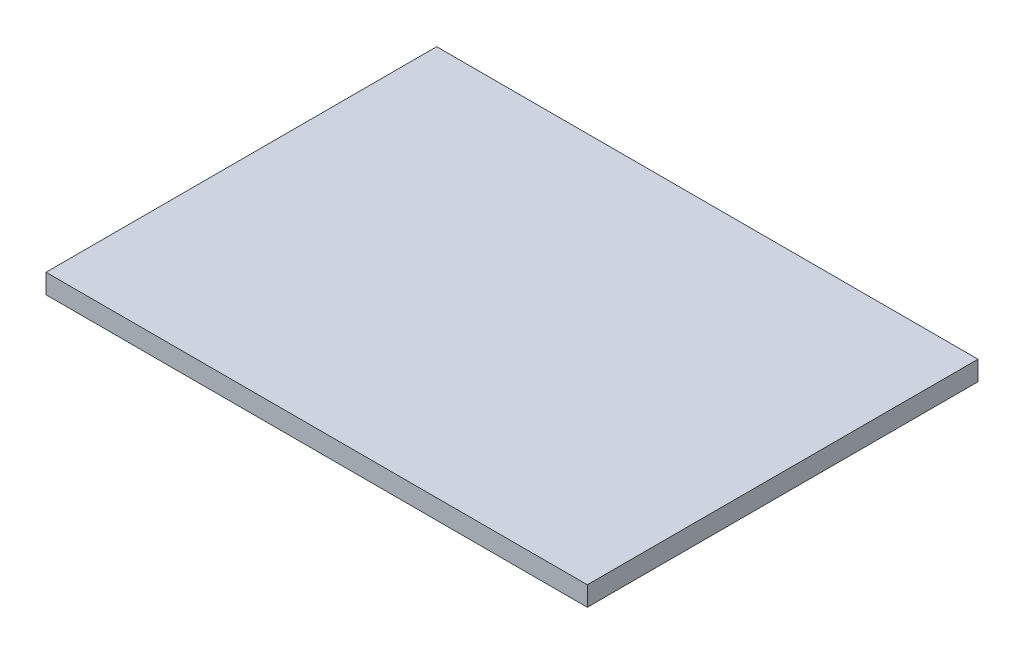
from build123d import *

# Parameters (mm, degrees)
SKETCH1_W           = 175.97628
SKETCH1_H           = 127
BOSS_EXTRUDE3_DEPTH = 6.35


with BuildPart() as part:
    # Sketch1 → Boss-Extrude3 (new body)
    with BuildSketch(Plane(origin=(0, 0, 0), x_dir=(1, 0, 0), z_dir=(0, 1, 0))):
        with Locations((-87.98814, 63.5)):
            Rectangle(SKETCH1_W, SKETCH1_H)
    extrude(amount=BOSS_EXTRUDE3_DEPTH)


solid = part.part
